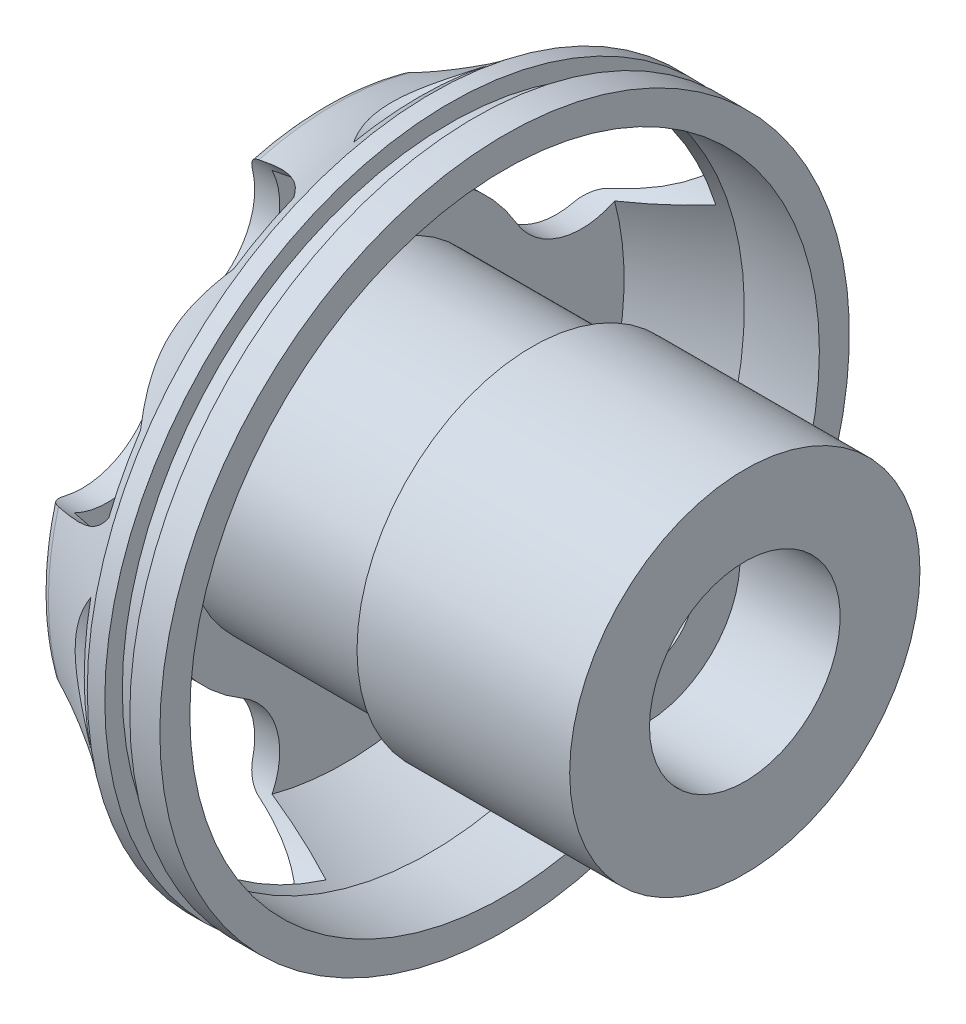
from build123d import *

# Parameters (mm, degrees)
FILLET1_R          = 1
CUT_EXTRUDE3_DEPTH = 4
SKETCH3_R          = 1.524
CUT_EXTRUDE4_DEPTH = 4


with BuildPart() as part:
    # Sketch1 → Revolve1 (revolve)
    with BuildSketch(Plane.XY):
        with BuildLine():
            Line((17, 3.81), (13, 3.81))
            Line((13, 3.81), (13, 2))
            Line((13, 2), (4, 2))
            Line((4, 2), (4, 3.81))
            Line((4, 3.81), (0, 3.81))
            Line((0, 3.81), (0, 11.176))
            ThreePointArc((0, 11.176), (2.34323383, 12.316600687), (4.5, 13.7795))
            Line((4.5, 13.7795), (5.2, 13.7795))
            Line((5.2, 13.7795), (5.2, 13.0795))
            Line((5.2, 13.0795), (6.2, 13.0795))
            Line((6.2, 13.0795), (6.2, 13.7795))
            Line((6.2, 13.7795), (7.4, 13.7795))
            Line((7.4, 13.7795), (7.4, 12.5795))
            Line((7.4, 12.5795), (4.4, 12.5795))
            Line((4.4, 12.5795), (1, 11.176))
            Line((1, 11.176), (1, 6.35))
            Line((1, 6.35), (8.5, 6.35))
            Line((8.5, 6.35), (8.5, 7))
            Line((8.5, 7), (17, 7))
            Line((17, 7), (17, 3.81))
        make_face()
    revolve(axis=Axis((0, 0, 0), (1, 0, 0)))

    # Fillet1
    fillet1_edges = [part.edges().sort_by_distance(p)[0] for p in [
        (0, -11.176, 0),
    ]]
    fillet(fillet1_edges, radius=FILLET1_R)

    # Sketch2 → Cut-Extrude3 (cut)
    with BuildSketch(Plane.ZY):
        with BuildLine():
            ThreePointArc((12.06001849, 7.110271022), (9.899494937, 9.899494937), (7.110271022, 12.06001849))
            ThreePointArc((7.110271022, 12.06001849), (3.002351841, 10.999358319), (4.063012013, 6.891439137))
            ThreePointArc((4.063012013, 6.891439137), (5.656854249, 5.656854249), (6.891439137, 4.063012013))
            ThreePointArc((6.891439137, 4.063012013), (10.999358319, 3.002351841), (12.06001849, 7.110271022))
        make_face()
        with BuildLine():
            ThreePointArc((7.196388958, 11.751025752), (8.935098107, 8.935098107), (11.751025752, 7.196388958))
            ThreePointArc((11.751025752, 7.196388958), (9.743577891, 9.743577891), (7.196388958, 11.751025752))
        make_face(mode=Mode.SUBTRACT)
        with BuildLine():
            ThreePointArc((4.063012013, -6.891439137), (5.656854249, -5.656854249), (6.891439137, -4.063012013))
            ThreePointArc((6.891439137, -4.063012013), (10.999358319, -3.002351841), (12.06001849, -7.110271022))
            ThreePointArc((12.06001849, -7.110271022), (9.899494937, -9.899494937), (7.110271022, -12.06001849))
            ThreePointArc((7.110271022, -12.06001849), (3.002351841, -10.999358319), (4.063012013, -6.891439137))
        make_face()
        with BuildLine():
            ThreePointArc((11.751025752, -7.196388958), (8.935098107, -8.935098107), (7.196388958, -11.751025752))
            ThreePointArc((7.196388958, -11.751025752), (9.743577891, -9.743577891), (11.751025752, -7.196388958))
        make_face(mode=Mode.SUBTRACT)
        with BuildLine():
            ThreePointArc((-6.891439137, -4.063012013), (-5.656854249, -5.656854249), (-4.063012013, -6.891439137))
            ThreePointArc((-4.063012013, -6.891439137), (-3.002351841, -10.999358319), (-7.110271022, -12.06001849))
            ThreePointArc((-7.110271022, -12.06001849), (-9.899494937, -9.899494937), (-12.06001849, -7.110271022))
            ThreePointArc((-12.06001849, -7.110271022), (-10.999358319, -3.002351841), (-6.891439137, -4.063012013))
        make_face()
        with BuildLine():
            ThreePointArc((-7.196388958, -11.751025752), (-8.935098107, -8.935098107), (-11.751025752, -7.196388958))
            ThreePointArc((-11.751025752, -7.196388958), (-9.743577891, -9.743577891), (-7.196388958, -11.751025752))
        make_face(mode=Mode.SUBTRACT)
        with BuildLine():
            ThreePointArc((-4.063012013, 6.891439137), (-5.656854249, 5.656854249), (-6.891439137, 4.063012013))
            ThreePointArc((-6.891439137, 4.063012013), (-10.999358319, 3.002351841), (-12.06001849, 7.110271022))
            ThreePointArc((-12.06001849, 7.110271022), (-9.899494937, 9.899494937), (-7.110271022, 12.06001849))
            ThreePointArc((-7.110271022, 12.06001849), (-3.002351841, 10.999358319), (-4.063012013, 6.891439137))
        make_face()
        with BuildLine():
            ThreePointArc((-11.751025752, 7.196388958), (-8.935098107, 8.935098107), (-7.196388958, 11.751025752))
            ThreePointArc((-7.196388958, 11.751025752), (-9.743577891, 9.743577891), (-11.751025752, 7.196388958))
        make_face(mode=Mode.SUBTRACT)
        with BuildLine():
            ThreePointArc((13.397845427, 3.220614563), (12.636136924, 0), (13.397845427, -3.220614563))
            ThreePointArc((13.397845427, -3.220614563), (13.7795, 0), (13.397845427, 3.220614563))
        make_face()
        with BuildLine():
            ThreePointArc((3.220614563, -13.397845427), (0, -12.636136924), (-3.220614563, -13.397845427))
            ThreePointArc((-3.220614563, -13.397845427), (0, -13.7795), (3.220614563, -13.397845427))
        make_face()
        with BuildLine():
            ThreePointArc((-13.397845427, -3.220614563), (-12.636136924, 0), (-13.397845427, 3.220614563))
            ThreePointArc((-13.397845427, 3.220614563), (-13.7795, 0), (-13.397845427, -3.220614563))
        make_face()
        with BuildLine():
            ThreePointArc((-3.220614563, 13.397845427), (0, 12.636136924), (3.220614563, 13.397845427))
            ThreePointArc((3.220614563, 13.397845427), (0, 13.7795), (-3.220614563, 13.397845427))
        make_face()
    extrude(amount=-CUT_EXTRUDE3_DEPTH, mode=Mode.SUBTRACT)

    # Sketch3 → Cut-Extrude4 (cut)
    with BuildSketch(Plane.ZY):
        with Locations((4.4577, 0)):
            Circle(SKETCH3_R)
        with Locations((-4.4577, 0)):
            Circle(SKETCH3_R)
        with Locations((0, -4.4577)):
            Circle(SKETCH3_R)
        with Locations((0, 4.4577)):
            Circle(SKETCH3_R)
    extrude(amount=-CUT_EXTRUDE4_DEPTH, mode=Mode.SUBTRACT)


solid = part.part
